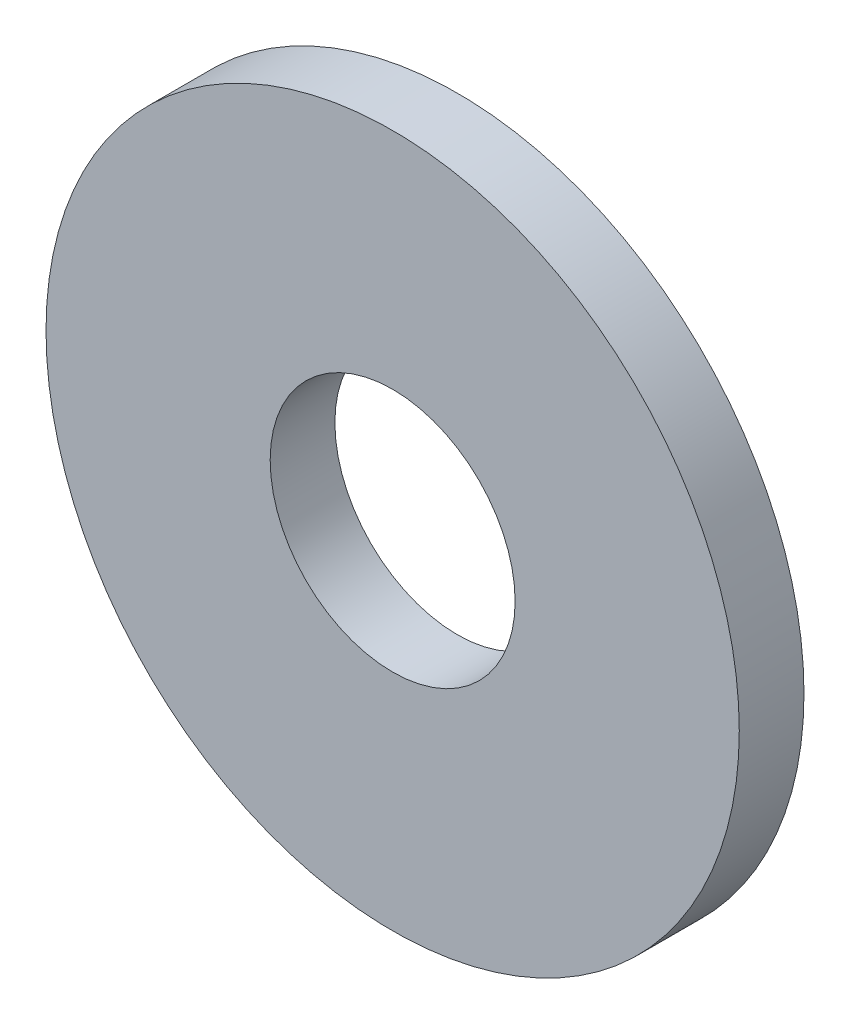
from build123d import *

# Parameters (mm, degrees)
SKETCH1_R           = 7.5
SKETCH1_R_2         = 2.65
BOSS_EXTRUDE1_DEPTH = 1.4


with BuildPart() as part:
    # Sketch1 → Boss-Extrude1 (new body)
    with BuildSketch(Plane.XY):
        Circle(SKETCH1_R)
        Circle(SKETCH1_R_2, mode=Mode.SUBTRACT)
    extrude(amount=BOSS_EXTRUDE1_DEPTH)


solid = part.part
